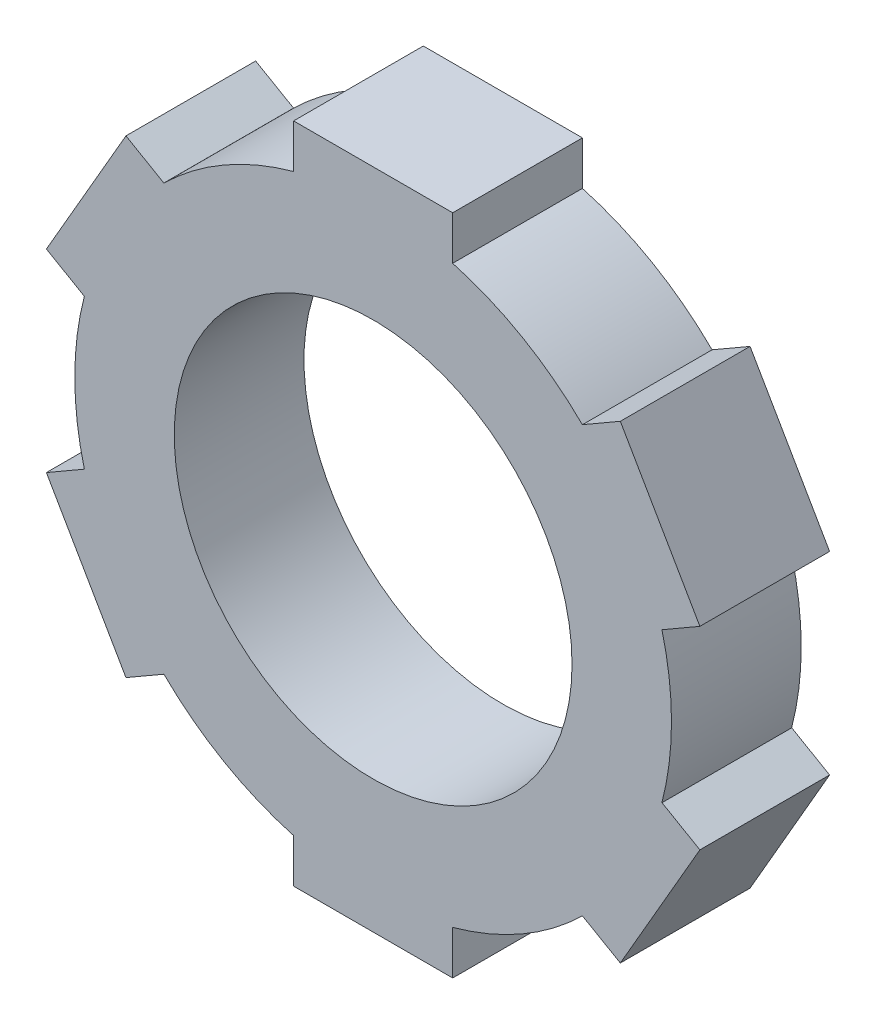
from build123d import *

# Parameters (mm, degrees)
SKETCH2_R           = 17.25
SKETCH2_R_2         = 11.5
BOSS_EXTRUDE1_DEPTH = 3.75
BOSS_EXTRUDE2_START = -3.75
SKETCH3_W           = 9.2
SKETCH3_H           = 2.53
BOSS_EXTRUDE2_DEPTH = 7.5
CIRPATTERN1_COUNT   = 6


with BuildPart() as part:
    # Sketch2 → Boss-Extrude1 (new body, symmetric)
    with BuildSketch(Plane.XY):
        Circle(SKETCH2_R)
        Circle(SKETCH2_R_2, mode=Mode.SUBTRACT)
    extrude(amount=BOSS_EXTRUDE1_DEPTH, both=True)

    # Sketch3 → Boss-Extrude2 (add)
    with BuildSketch(Plane.XY.offset(BOSS_EXTRUDE2_START)):
        with Locations((0, 17.894)):
            Rectangle(SKETCH3_W, SKETCH3_H)
    boss_extrude2 = extrude(amount=BOSS_EXTRUDE2_DEPTH)

    # CirPattern1: Boss-Extrude2 ×6 about axis
    cirpattern1_axis = Axis((0, 0, 0), (0, 0, 1))
    for i in range(1, CIRPATTERN1_COUNT):
        add(boss_extrude2.rotate(cirpattern1_axis, i * 360 / CIRPATTERN1_COUNT))


solid = part.part
